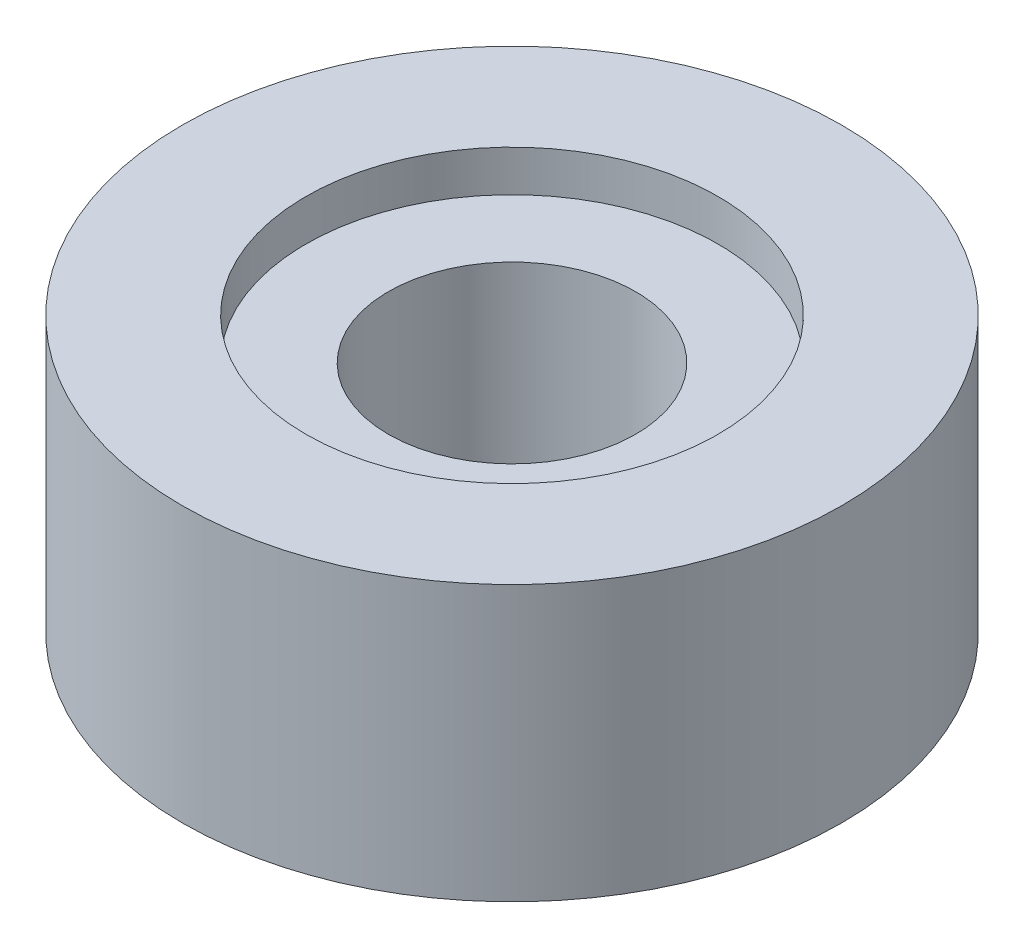
from build123d import *

# Parameters (mm, degrees)
ESQUISSE1_R             = 6
BOSS_EXTRU_1_DEPTH      = 5
ENL_V_MAT_EXTRU_1_REACH = 7
ESQUISSE2_R             = 2.25
ESQUISSE3_R             = 3.75
ENL_V_MAT_EXTRU_2_DEPTH = 0.75


with BuildPart() as part:
    # Esquisse1 → Boss.-Extru.1 (new body)
    with BuildSketch(Plane(origin=(0, 0, 0), x_dir=(1, 0, 0), z_dir=(0, 1, 0))):
        Circle(ESQUISSE1_R)
    extrude(amount=BOSS_EXTRU_1_DEPTH)

    # Esquisse2 → Enlèv. mat.-Extru.1 (cut, up to next)
    with BuildSketch(Plane(origin=(0, 5, 0), x_dir=(1, 0, 0), z_dir=(0, 1, 0)), mode=Mode.PRIVATE) as enl_v_mat_extru_1_sk1:
        Circle(ESQUISSE2_R)
    enl_v_mat_extru_1_tool1 = extrude(enl_v_mat_extru_1_sk1.sketch, amount=-ENL_V_MAT_EXTRU_1_REACH, mode=Mode.PRIVATE) & part.part
    add(enl_v_mat_extru_1_tool1.solids().sort_by_distance((0, 5, 0))[0], mode=Mode.SUBTRACT)

    # Esquisse3 → Enlèv. mat.-Extru.2 (cut)
    with BuildSketch(Plane(origin=(0, 5, 0), x_dir=(1, 0, 0), z_dir=(0, 1, 0))):
        Circle(ESQUISSE3_R)
    extrude(amount=-ENL_V_MAT_EXTRU_2_DEPTH, mode=Mode.SUBTRACT)


solid = part.part
